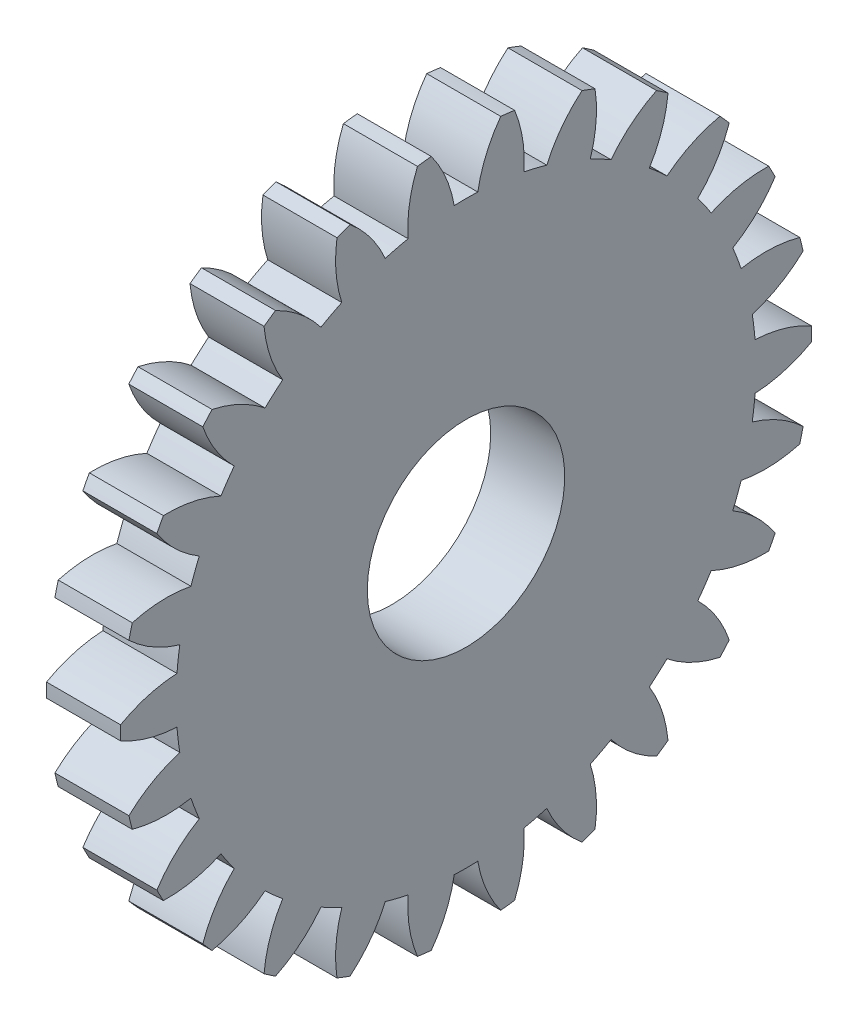
from build123d import *

# Parameters (mm, degrees)
BASPROSKE_W     = 3
BASPROSKE_H     = 14
TOOTHCUT_DEPTH  = 21.024984395
TEETHCUTS_COUNT = 26
TEETHCUTS_ANGLE = 346.153846154
BORSKE_R        = 4
BORE_DEPTH      = 50.0000508


with BuildPart() as part:
    # BasProSke → Base-Revolve (revolve)
    with BuildSketch(Plane(origin=(0, 0, 0), x_dir=(1, 0, 0), z_dir=(0, 1, 0)), mode=Mode.PRIVATE) as base_revolve_sk:
        with Locations((1.5, 7)):
            Rectangle(BASPROSKE_W, BASPROSKE_H)
    revolve(base_revolve_sk.sketch.rotate(Axis((-10, 0, 0), (1, 0, 0)), 180), axis=Axis((-10, 0, 0), (1, 0, 0)))

    # TooCutSke → ToothCut (cut, through all)
    with BuildSketch(Plane(origin=(0, 0, 0), x_dir=(0, 0, -1), z_dir=(1, 0, 0))):
        with BuildLine():
            ThreePointArc((0.476965065, 11.739314517), (0, 11.749), (-0.476965065, 11.739314517))
            ThreePointArc((-0.476965065, 11.739314517), (-0.82065865, 12.901686978), (-1.424117301, 13.952911348))
            ThreePointArc((-1.424117301, 13.952911348), (0, 14.0254), (1.424117301, 13.952911348))
            ThreePointArc((1.424117301, 13.952911348), (0.82065865, 12.901686978), (0.476965065, 11.739314517))
        make_face()
    toothcut = extrude(amount=TOOTHCUT_DEPTH, mode=Mode.SUBTRACT)

    # TeethCuts: ToothCut ×26 about axis
    teethcuts_axis = Axis((-10, 0, 0), (1, 0, 0))
    for i in range(1, TEETHCUTS_COUNT):
        add(toothcut.rotate(teethcuts_axis, i * TEETHCUTS_ANGLE / (TEETHCUTS_COUNT - 1)), mode=Mode.SUBTRACT)

    # BorSke → Bore (cut, symmetric)
    with BuildSketch(Plane(origin=(0, 0, 0), x_dir=(0, 0, -1), z_dir=(1, 0, 0))):
        with Locations(Location((0, 0, 0), (0, 0, 180))):
            Circle(BORSKE_R)
    extrude(amount=BORE_DEPTH, both=True, mode=Mode.SUBTRACT)


solid = part.part
